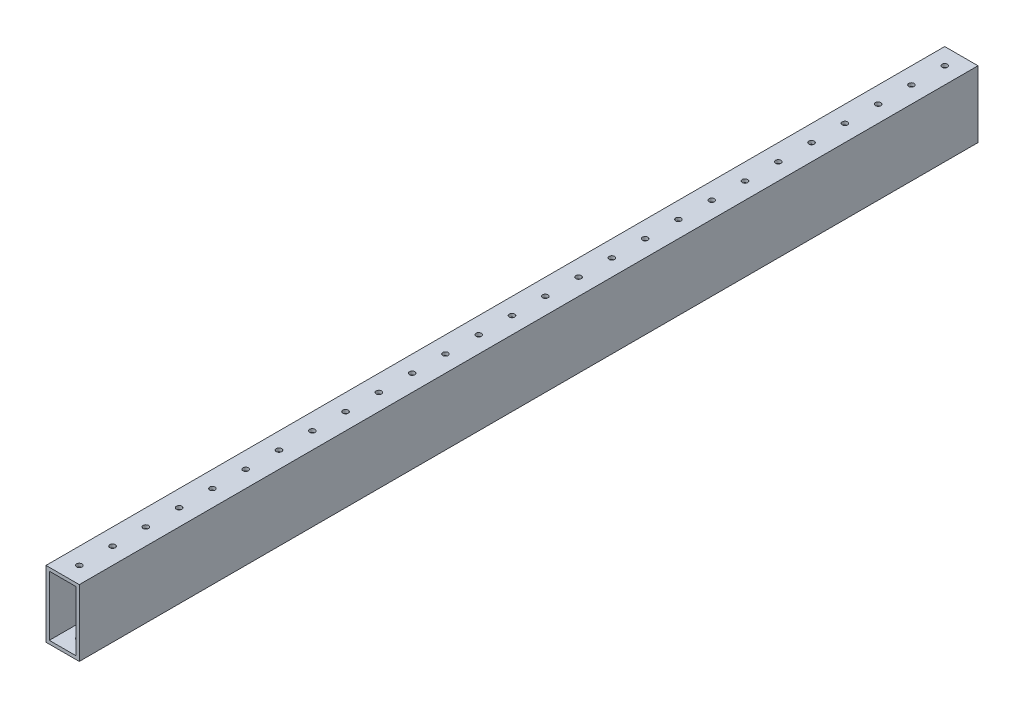
from build123d import *

# Parameters (mm, degrees)
SKETCH1_W           = 25.4
SKETCH1_H           = 50.8
SKETCH1_W_2         = 20.32
SKETCH1_H_2         = 45.72
EXTRUDE_THIN1_DEPTH = 342.9
SKETCH2_R           = 2.0701
CUT_EXTRUDE1_DEPTH  = 51.8
LPATTERN1_COUNT     = 28
LPATTERN1_PITCH     = 25.4


with BuildPart() as part:
    # Sketch1 → Extrude-Thin1 (new body, symmetric)
    with BuildSketch(Plane.XY):
        Rectangle(SKETCH1_W, SKETCH1_H)
        Rectangle(SKETCH1_W_2, SKETCH1_H_2, mode=Mode.SUBTRACT)
    extrude(amount=EXTRUDE_THIN1_DEPTH, both=True)

    # Sketch2 → Cut-Extrude1 (cut, through all)
    with BuildSketch(Plane(origin=(0, 25.4, 0), x_dir=(1, 0, 0), z_dir=(0, 1, 0))):
        with Locations((0, -330.2)):
            Circle(SKETCH2_R)
    cut_extrude1 = extrude(amount=-CUT_EXTRUDE1_DEPTH, mode=Mode.SUBTRACT)

    # LPattern1: Cut-Extrude1 ×28
    with Locations(*[(0, 0, -i * LPATTERN1_PITCH) for i in range(1, LPATTERN1_COUNT)]):
        add(cut_extrude1, mode=Mode.SUBTRACT)


solid = part.part
